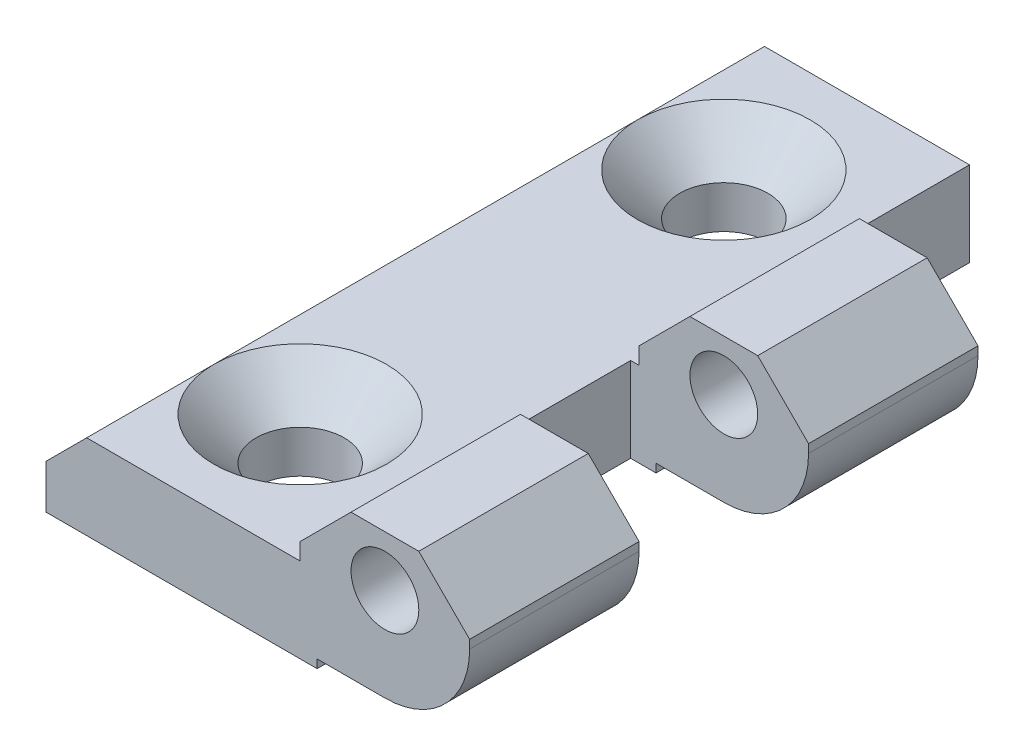
from build123d import *

# Parameters (mm, degrees)
SKETCH1_R               = 2
EXTRUDE1_DEPTH          = 40
CUT_EXTRUDE1_DEPTH      = 5
CUT_EXTRUDE1_DEPTH_BACK = 6
HOLE1_AT_2_COUNT        = 2
HOLE1_AT_2_PITCH        = 25


with BuildPart() as part:
    # Sketch1 → Extrude1 (new body)
    with BuildSketch(Plane.XY):
        with BuildLine():
            Line((-31.475233645, -9.996703011), (-15.475233645, -9.996703011))
            Line((-15.475233645, -9.996703011), (-15.475233645, -9.496703011))
            Line((-15.475233645, -9.496703011), (-11.475233645, -9.496703011))
            ThreePointArc((-11.475233645, -9.496703011), (-7.939699739, -8.032236917), (-6.475233645, -4.496703011))
            Line((-6.475233645, -4.496703011), (-6.475233645, -3.996703011))
            Line((-6.475233645, -3.996703011), (-9.475233645, -0.996703011))
            Line((-9.475233645, -0.996703011), (-13.475233645, -0.996703011))
            Line((-13.475233645, -0.996703011), (-16.475233645, -3.996703011))
            Line((-16.475233645, -3.996703011), (-16.475233645, -4.996703011))
            Line((-16.475233645, -4.996703011), (-29.075233645, -4.996703011))
            Line((-29.075233645, -4.996703011), (-31.475233645, -7.396703011))
            Line((-31.475233645, -7.396703011), (-31.475233645, -9.996703011))
        make_face()
        with Locations((-11.475233645, -3.996703011)):
            Circle(SKETCH1_R, mode=Mode.SUBTRACT)
    extrude(amount=EXTRUDE1_DEPTH)

    # Sketch2 → Cut-Extrude1 (cut, two sides)
    with BuildSketch(Plane(origin=(0, -4.996703011, 0), x_dir=(1, 0, 0), z_dir=(0, 1, 0))) as cut_extrude1_sk:
        Polygon((-9.475233645, -20), (-16.975233645, -20), (-16.975233645, -28.700140492), (-16.975233645, -30), (-3.073130332, -30), (-3.073130332, -20), align=None)
        Polygon((-9.475233645, -10), (-16.975233645, -10), (-16.975233645, 0), (-9.475233645, 0), (-4.909711278, 0), (-4.909711278, -10), align=None)
    extrude(amount=CUT_EXTRUDE1_DEPTH, mode=Mode.SUBTRACT)
    extrude(cut_extrude1_sk.sketch, amount=-CUT_EXTRUDE1_DEPTH_BACK, mode=Mode.SUBTRACT)

    # Sketch4 → Hole1 (revolve, cut)
    with BuildSketch(Plane(origin=(-23.975233645, -4.996703011, 7.5), x_dir=(0, 0, 1), z_dir=(1, 0, 0))):
        Polygon((0, 0), (0, 5), (2.6, 5), (2.6, 2.5), (5.1, 0), align=None)
    hole1 = revolve(axis=Axis((-23.975233645, 1.353296989, 7.5), (0, -1, 0)), mode=Mode.SUBTRACT)

    # Hole1 at 2: Hole1 ×2
    with Locations(*[(0, 0, i * HOLE1_AT_2_PITCH) for i in range(1, HOLE1_AT_2_COUNT)]):
        add(hole1, mode=Mode.SUBTRACT)


solid = part.part
